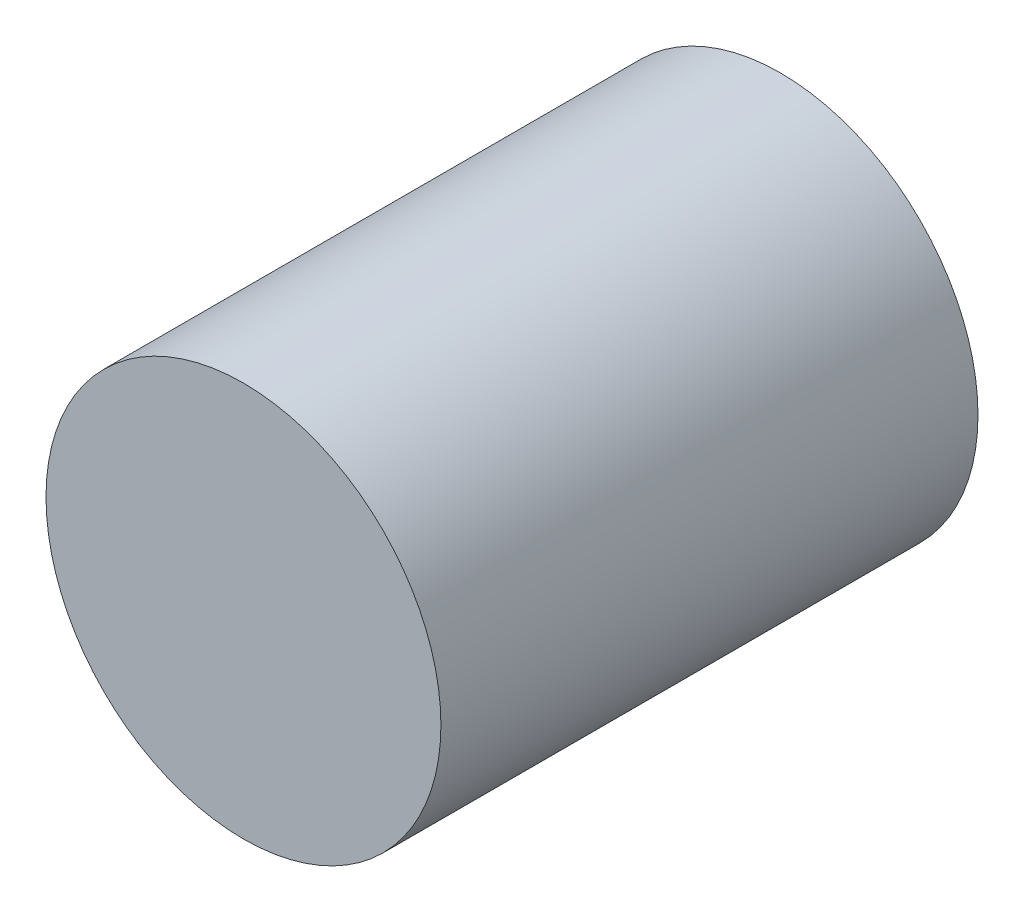
from build123d import *

# Parameters (mm, degrees)
SKETCH1_R  = 12.5
BASE_DEPTH = 34


with BuildPart() as part:
    # Sketch1 → base (new body)
    with BuildSketch(Plane.XY):
        Circle(SKETCH1_R)
    extrude(amount=BASE_DEPTH)


solid = part.part
